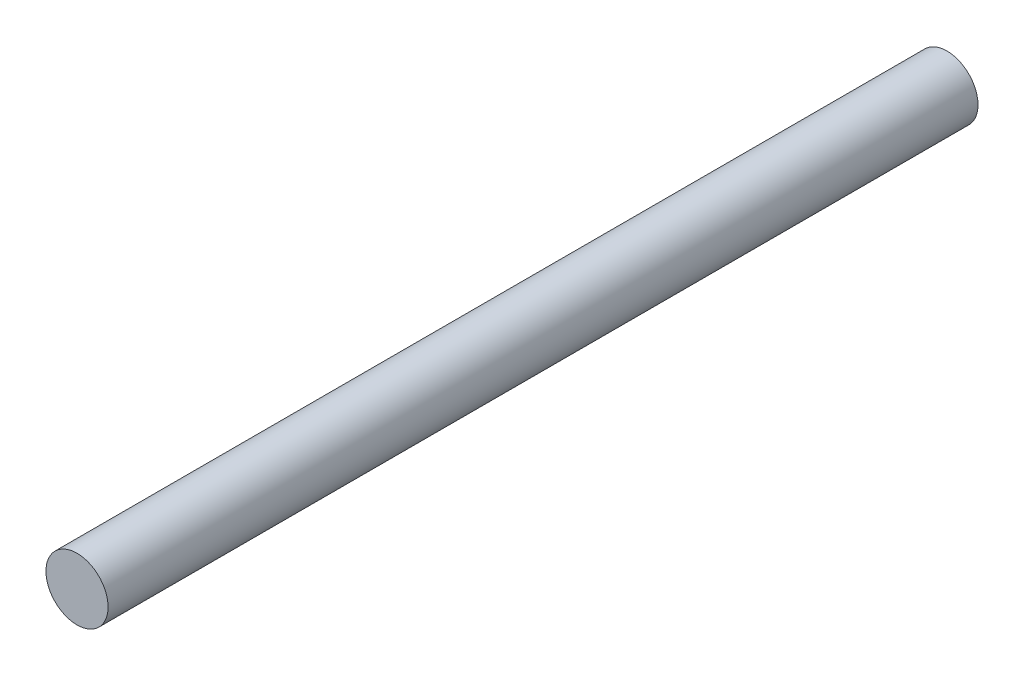
from build123d import *

# Parameters (mm, degrees)
SKETCH1_R           = 5
BOSS_EXTRUDE1_DEPTH = 70


with BuildPart() as part:
    # Sketch1 → Boss-Extrude1 (new body, symmetric)
    with BuildSketch(Plane.XY):
        Circle(SKETCH1_R)
    extrude(amount=BOSS_EXTRUDE1_DEPTH, both=True)


solid = part.part
